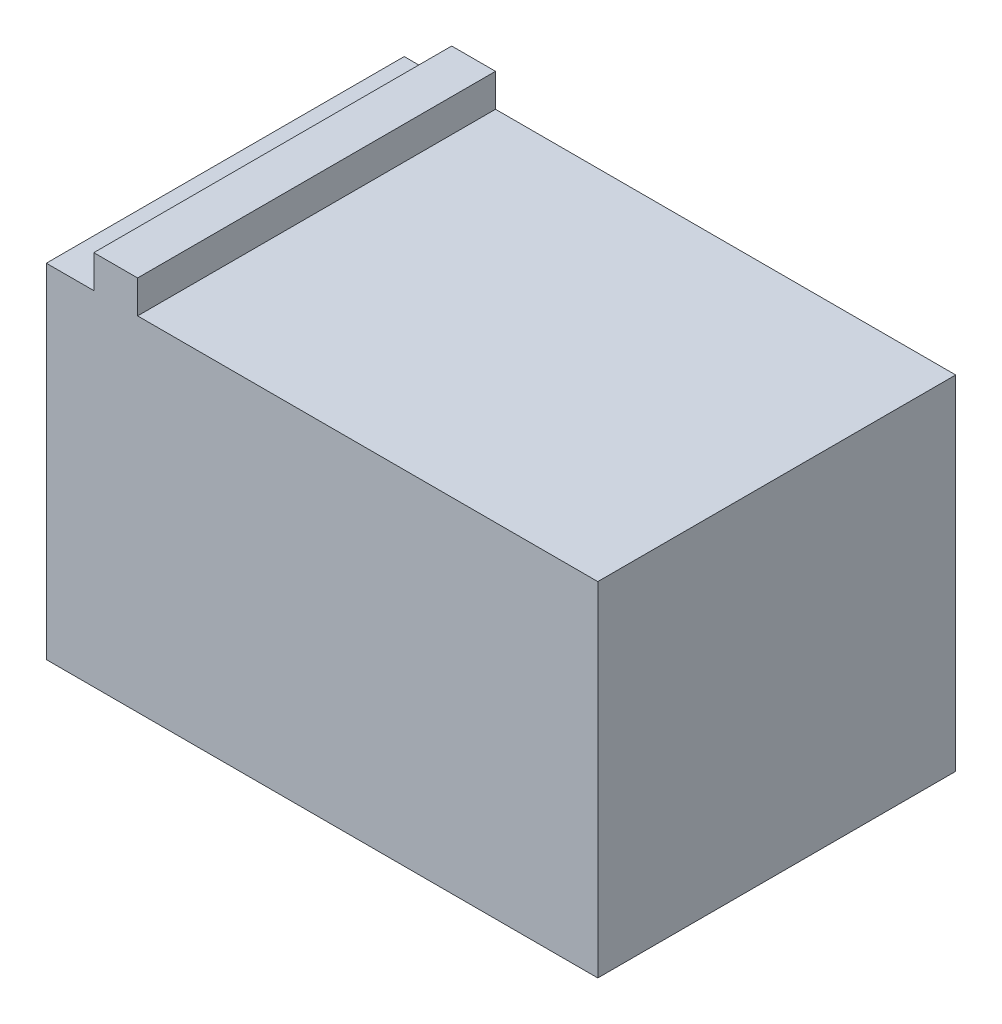
from build123d import *

# Parameters (mm, degrees)
SKETCH_1_W      = 151
SKETCH_1_H      = 98
EXTRUDE_1_DEPTH = 94
SKETCH_2_W      = 12
SKETCH_2_H      = 98
EXTRUDE_2_DEPTH = 9


with BuildPart() as part:
    # Эскиз1 → Бобышка-Вытянуть1 (new body)
    with BuildSketch(Plane(origin=(0, 0, 0), x_dir=(1, 0, 0), z_dir=(0, 1, 0))):
        Rectangle(SKETCH_1_W, SKETCH_1_H)
    extrude(amount=EXTRUDE_1_DEPTH)

    # Эскиз2 → Бобышка-Вытянуть2 (add)
    with BuildSketch(Plane(origin=(0, 94, 0), x_dir=(1, 0, 0), z_dir=(0, 1, 0))):
        with Locations((-56.5, 0)):
            Rectangle(SKETCH_2_W, SKETCH_2_H)
    extrude(amount=EXTRUDE_2_DEPTH)


solid = part.part
